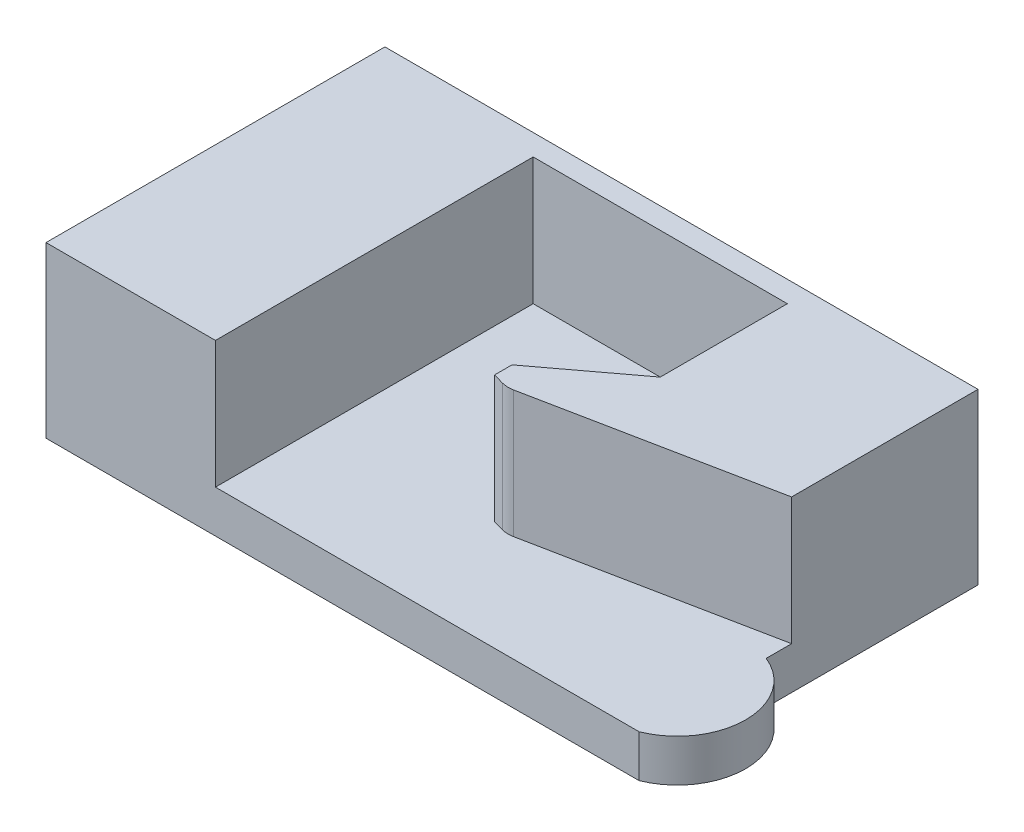
from build123d import *

# Parameters (mm, degrees)
SKETCH1_W           = 70
SKETCH1_H           = 40
BOSS_EXTRUDE1_DEPTH = 20
CUT_EXTRUDE1_DEPTH  = 15
SKETCH3_W           = 20
SKETCH3_H           = 15
CUT_EXTRUDE2_DEPTH  = 15
CUT_EXTRUDE3_DEPTH  = 15
CHAMFER1_SIZE       = 2
CHAMFER1_SIZE2      = 0.943123045
FILLET1_R           = 3
BOSS_EXTRUDE2_DEPTH = 5


with BuildPart() as part:
    # Sketch1 → Boss-Extrude1 (new body)
    with BuildSketch(Plane(origin=(0, 0, 0), x_dir=(1, 0, 0), z_dir=(0, 1, 0))):
        with Locations((35, 20)):
            Rectangle(SKETCH1_W, SKETCH1_H)
    extrude(amount=BOSS_EXTRUDE1_DEPTH)

    # Sketch2 → Cut-Extrude1 (cut)
    with BuildSketch(Plane(origin=(0, 20, 0), x_dir=(1, 0, 0), z_dir=(0, 1, 0))):
        Polygon((20, 15), (20, 37.5), (50, 37.5), (50, 22.5), (40, 15), align=None)
    extrude(amount=-CUT_EXTRUDE1_DEPTH, mode=Mode.SUBTRACT)

    # Sketch3 → Cut-Extrude2 (cut)
    with BuildSketch(Plane(origin=(0, 20, 0), x_dir=(1, 0, 0), z_dir=(0, 1, 0))):
        with Locations((30, 7.5)):
            Rectangle(SKETCH3_W, SKETCH3_H)
    extrude(amount=-CUT_EXTRUDE2_DEPTH, mode=Mode.SUBTRACT)

    # Sketch4 → Cut-Extrude3 (cut)
    with BuildSketch(Plane(origin=(0, 20, 0), x_dir=(1, 0, 0), z_dir=(0, 1, 0))):
        Polygon((40, 12), (70, 18), (70, 0), (40, 0), align=None)
    extrude(amount=-CUT_EXTRUDE3_DEPTH, mode=Mode.SUBTRACT)

    # Chamfer1
    chamfer1_edges = [part.edges().sort_by_distance(p)[0] for p in [
        (40, 12.5, -12),
    ]]
    chamfer1_side = [part.faces().sort_by_distance(p)[0] for p in [
        (55, 12.5, -15),
    ]]
    chamfer(chamfer1_edges, length=CHAMFER1_SIZE, length2=CHAMFER1_SIZE2, reference=chamfer1_side[0])

    # Fillet1
    fillet1_edges = [part.edges().sort_by_distance(p)[0] for p in [
        (41.961161351, 12.5, -12.39223227),
    ]]
    fillet(fillet1_edges, radius=FILLET1_R)

    # Sketch5 → Boss-Extrude2 (add)
    with BuildSketch(Plane.XZ):
        with BuildLine():
            Line((70, -15), (70, 0))
            ThreePointArc((70, 0), (75.077747211, -7.5), (70, -15))
        make_face()
    extrude(amount=-BOSS_EXTRUDE2_DEPTH)


solid = part.part
